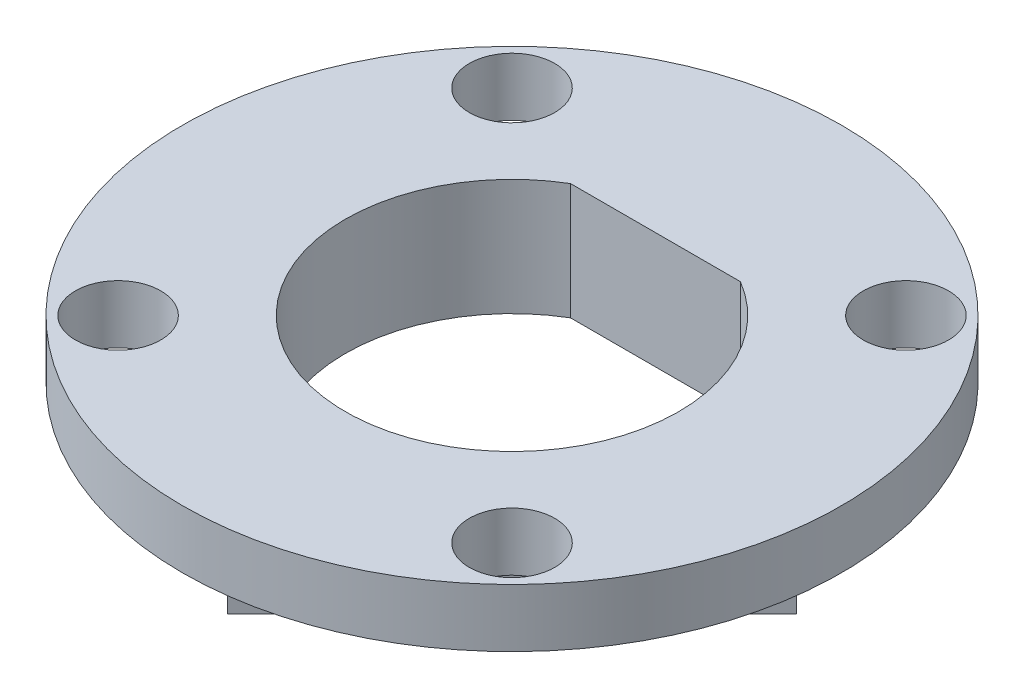
from build123d import *

# Parameters (mm, degrees)
SKETCH_1_R               = 8.5
EXTRUDE_1_DEPTH          = 3
CUT_EXTRUDE_1_DEPTH      = 3
SKETCH_3_R               = 1.1
CUT_EXTRUDE_2_DEPTH      = 3
CUT_EXTRUDE_3_DEPTH      = 1.5
PATTERN_CIRCULAR_1_COUNT = 4


with BuildPart() as part:
    # 스케치1 → 보스-돌출1 (new body)
    with BuildSketch(Plane(origin=(0, 0, 0), x_dir=(1, 0, 0), z_dir=(0, 1, 0))):
        Circle(SKETCH_1_R)
    extrude(amount=EXTRUDE_1_DEPTH)

    # 스케치2 → 컷-돌출1 (cut)
    with BuildSketch(Plane(origin=(0, 3, 0), x_dir=(1, 0, 0), z_dir=(0, 1, 0))):
        with BuildLine():
            Line((-2.19089023, 3.7), (2.19089023, 3.7))
            ThreePointArc((2.19089023, 3.7), (0, -4.3), (-2.19089023, 3.7))
        make_face()
    extrude(amount=-CUT_EXTRUDE_1_DEPTH, mode=Mode.SUBTRACT)

    # 스케치3 → 컷-돌출2 (cut)
    with BuildSketch(Plane(origin=(0, 3, 0), x_dir=(1, 0, 0), z_dir=(0, 1, 0))):
        with Locations((5.08, 5.08)):
            Circle(SKETCH_3_R)
        with Locations((-5.08, -5.08)):
            Circle(SKETCH_3_R)
        with Locations((5.08, -5.08)):
            Circle(SKETCH_3_R)
        with Locations((-5.08, 5.08)):
            Circle(SKETCH_3_R)
    extrude(amount=-CUT_EXTRUDE_2_DEPTH, mode=Mode.SUBTRACT)

    # 스케치4 → 컷-돌출3 (cut)
    with BuildSketch(Plane.XZ):
        with BuildLine():
            Line((1.097301825, 8.4288747), (-8.4288747, -1.097301825))
            ThreePointArc((-8.4288747, -1.097301825), (-6.01040764, 6.01040764), (1.097301825, 8.4288747))
        make_face()
    cut_extrude_3 = extrude(amount=-CUT_EXTRUDE_3_DEPTH, mode=Mode.SUBTRACT)

    # 원형 패턴1: 컷-돌출3 ×4 about axis
    pattern_circular_1_axis = Axis((0, 0, 0), (0, 1, 0))
    for i in range(1, PATTERN_CIRCULAR_1_COUNT):
        add(cut_extrude_3.rotate(pattern_circular_1_axis, i * 360 / PATTERN_CIRCULAR_1_COUNT), mode=Mode.SUBTRACT)


solid = part.part
